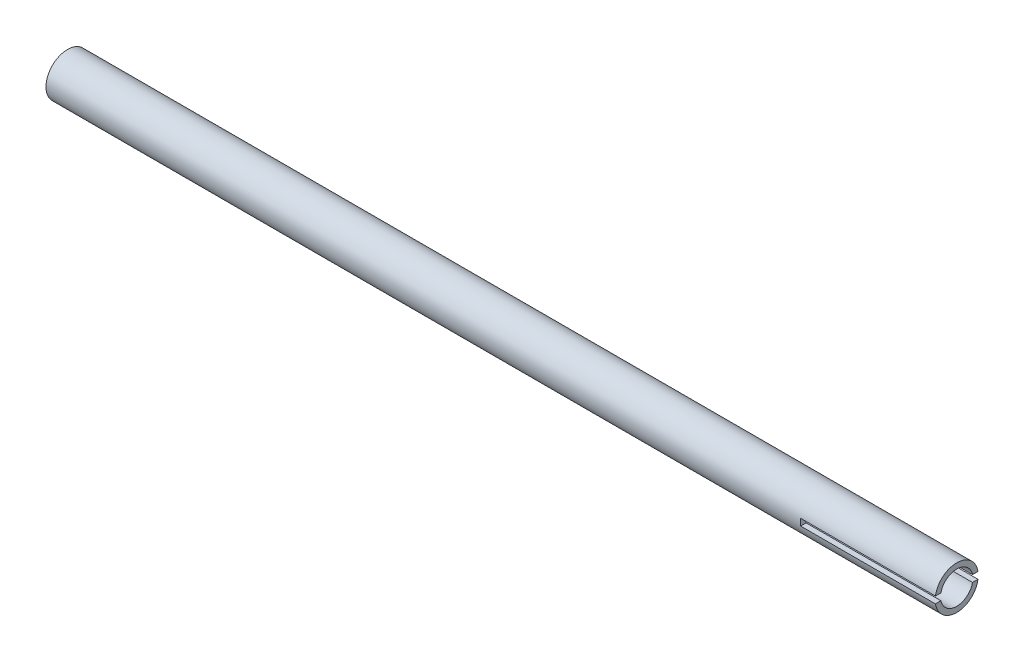
from build123d import *

# Parameters (mm, degrees)
SKETCH1_R               = 8
SKETCH1_R_2             = 6
BOSS_EXTRUDE1_DEPTH     = 165
SKETCH2_W               = 50
SKETCH2_H               = 2.5
CUT_EXTRUDE1_DEPTH      = 9
CUT_EXTRUDE1_DEPTH_BACK = 9


with BuildPart() as part:
    # Sketch1 → Boss-Extrude1 (new body, symmetric)
    with BuildSketch(Plane(origin=(0, 0, 0), x_dir=(0, 0, -1), z_dir=(1, 0, 0))):
        Circle(SKETCH1_R)
        Circle(SKETCH1_R_2, mode=Mode.SUBTRACT)
    extrude(amount=BOSS_EXTRUDE1_DEPTH, both=True)

    # Sketch2 → Cut-Extrude1 (cut, two sides)
    with BuildSketch(Plane.XY) as cut_extrude1_sk:
        with Locations((140, 0)):
            Rectangle(SKETCH2_W, SKETCH2_H)
    extrude(amount=CUT_EXTRUDE1_DEPTH, mode=Mode.SUBTRACT)
    extrude(cut_extrude1_sk.sketch, amount=-CUT_EXTRUDE1_DEPTH_BACK, mode=Mode.SUBTRACT)


solid = part.part
